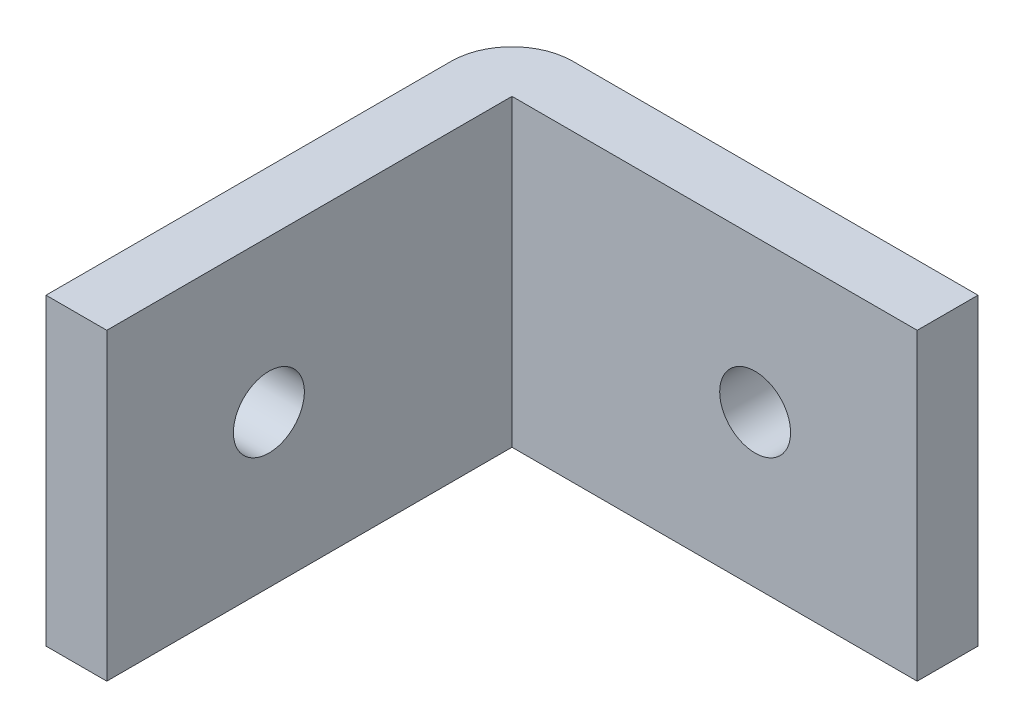
from build123d import *

# Parameters (mm, degrees)
SKETCH1_W           = 23
SKETCH1_H           = 15
BOSS_EXTRUDE1_DEPTH = 3
SKETCH10_W          = 3
SKETCH10_H          = 15
BOSS_EXTRUDE2_DEPTH = 20
SKETCH13_R          = 1.75
CUT_EXTRUDE3_DEPTH  = 24
SKETCH14_R          = 1.75
CUT_EXTRUDE4_DEPTH  = 24
FILLET1_R           = 3


with BuildPart() as part:
    # Sketch1 → Boss-Extrude1 (new body)
    with BuildSketch(Plane.XY):
        Rectangle(SKETCH1_W, SKETCH1_H)
    extrude(amount=BOSS_EXTRUDE1_DEPTH)

    # Sketch10 → Boss-Extrude2 (add)
    with BuildSketch(Plane.XY.offset(3)):
        with Locations((-10, 0)):
            Rectangle(SKETCH10_W, SKETCH10_H)
    extrude(amount=BOSS_EXTRUDE2_DEPTH)

    # Sketch13 → Cut-Extrude3 (cut, through all)
    with BuildSketch(Plane(origin=(0, 0, 0), x_dir=(-1, 0, 0), z_dir=(0, 0, -1))):
        with Locations((-3.5, 0)):
            Circle(SKETCH13_R)
    extrude(amount=-CUT_EXTRUDE3_DEPTH, mode=Mode.SUBTRACT)

    # Sketch14 → Cut-Extrude4 (cut, through all)
    with BuildSketch(Plane.ZY.offset(11.5)):
        with Locations((15, 0)):
            Circle(SKETCH14_R)
    extrude(amount=-CUT_EXTRUDE4_DEPTH, mode=Mode.SUBTRACT)

    # Fillet1
    fillet1_edges = [part.edges().sort_by_distance(p)[0] for p in [
        (-11.5, 0, 0),
    ]]
    fillet(fillet1_edges, radius=FILLET1_R)


solid = part.part
